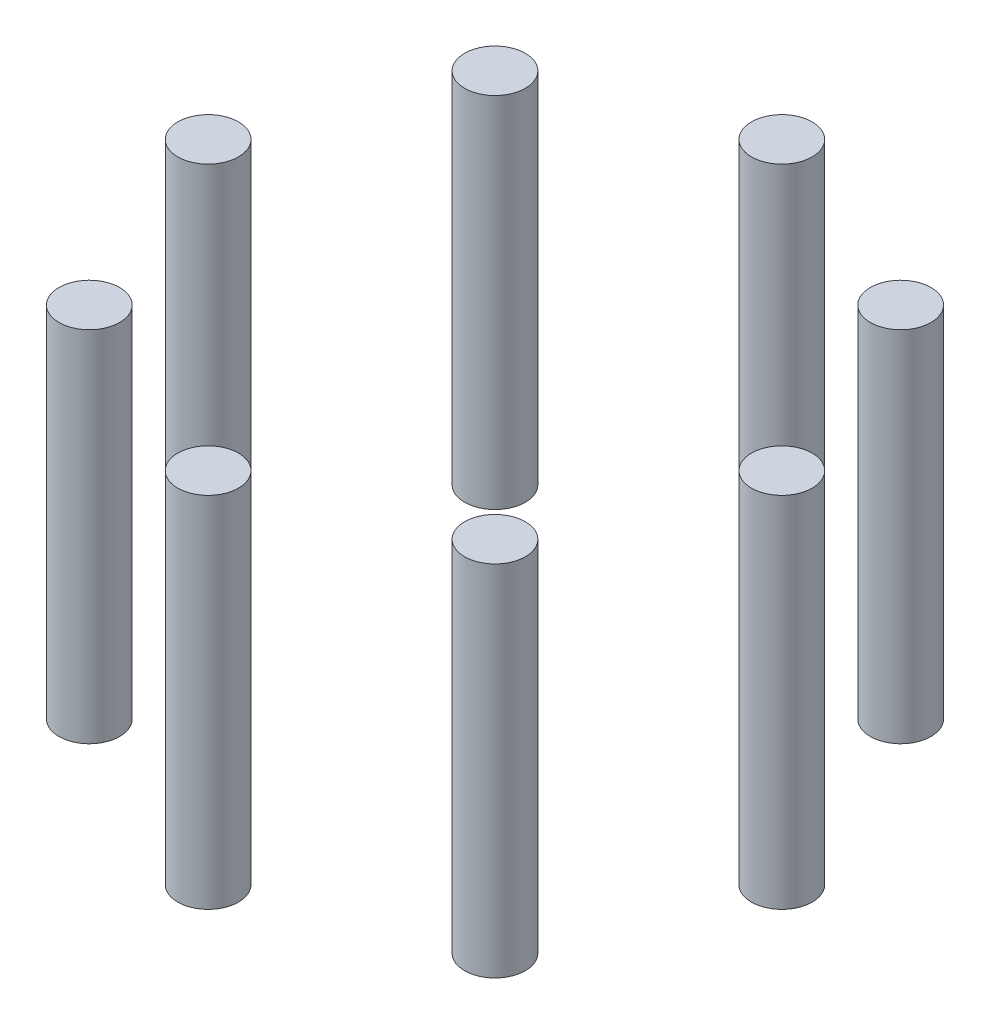
from build123d import *

# Parameters (mm, degrees)
SKETCH1_R             = 5.5
BOSS_EXTRUDE1_DEPTH   = 65
BOSS_EXTRUDE1_2_DEPTH = 65
BOSS_EXTRUDE1_3_DEPTH = 65
BOSS_EXTRUDE1_4_DEPTH = 65
BOSS_EXTRUDE1_5_DEPTH = 65
BOSS_EXTRUDE1_6_DEPTH = 65
BOSS_EXTRUDE1_7_DEPTH = 65
BOSS_EXTRUDE1_8_DEPTH = 65


with BuildPart() as part:
    # Sketch1 → Boss-Extrude1 (new body)
    with BuildSketch(Plane(origin=(0, 0, 0), x_dir=(1, 0, 0), z_dir=(0, 1, 0))):
        with Locations((-52, 0)):
            Circle(SKETCH1_R)
    extrude(amount=BOSS_EXTRUDE1_DEPTH)


with BuildPart() as body_2:
    # Sketch1 → Boss-Extrude1 2 (new body)
    with BuildSketch(Plane(origin=(0, 0, 0), x_dir=(1, 0, 0), z_dir=(0, 1, 0))):
        with Locations((-36.769552622, 36.769552622)):
            Circle(SKETCH1_R)
    extrude(amount=BOSS_EXTRUDE1_2_DEPTH)


with BuildPart() as body_3:
    # Sketch1 → Boss-Extrude1 3 (new body)
    with BuildSketch(Plane(origin=(0, 0, 0), x_dir=(1, 0, 0), z_dir=(0, 1, 0))):
        with Locations((0, 52)):
            Circle(SKETCH1_R)
    extrude(amount=BOSS_EXTRUDE1_3_DEPTH)


with BuildPart() as body_4:
    # Sketch1 → Boss-Extrude1 4 (new body)
    with BuildSketch(Plane(origin=(0, 0, 0), x_dir=(1, 0, 0), z_dir=(0, 1, 0))):
        with Locations((36.769552622, 36.769552622)):
            Circle(SKETCH1_R)
    extrude(amount=BOSS_EXTRUDE1_4_DEPTH)


with BuildPart() as body_5:
    # Sketch1 → Boss-Extrude1 5 (new body)
    with BuildSketch(Plane(origin=(0, 0, 0), x_dir=(1, 0, 0), z_dir=(0, 1, 0))):
        with Locations((52, 0)):
            Circle(SKETCH1_R)
    extrude(amount=BOSS_EXTRUDE1_5_DEPTH)


with BuildPart() as body_6:
    # Sketch1 → Boss-Extrude1 6 (new body)
    with BuildSketch(Plane(origin=(0, 0, 0), x_dir=(1, 0, 0), z_dir=(0, 1, 0))):
        with Locations((36.769552622, -36.769552622)):
            Circle(SKETCH1_R)
    extrude(amount=BOSS_EXTRUDE1_6_DEPTH)


with BuildPart() as body_7:
    # Sketch1 → Boss-Extrude1 7 (new body)
    with BuildSketch(Plane(origin=(0, 0, 0), x_dir=(1, 0, 0), z_dir=(0, 1, 0))):
        with Locations((0, -52)):
            Circle(SKETCH1_R)
    extrude(amount=BOSS_EXTRUDE1_7_DEPTH)


with BuildPart() as body_8:
    # Sketch1 → Boss-Extrude1 8 (new body)
    with BuildSketch(Plane(origin=(0, 0, 0), x_dir=(1, 0, 0), z_dir=(0, 1, 0))):
        with Locations((-36.769552622, -36.769552622)):
            Circle(SKETCH1_R)
    extrude(amount=BOSS_EXTRUDE1_8_DEPTH)


solid = Compound([part.part, body_2.part, body_3.part, body_4.part, body_5.part, body_6.part, body_7.part, body_8.part])
